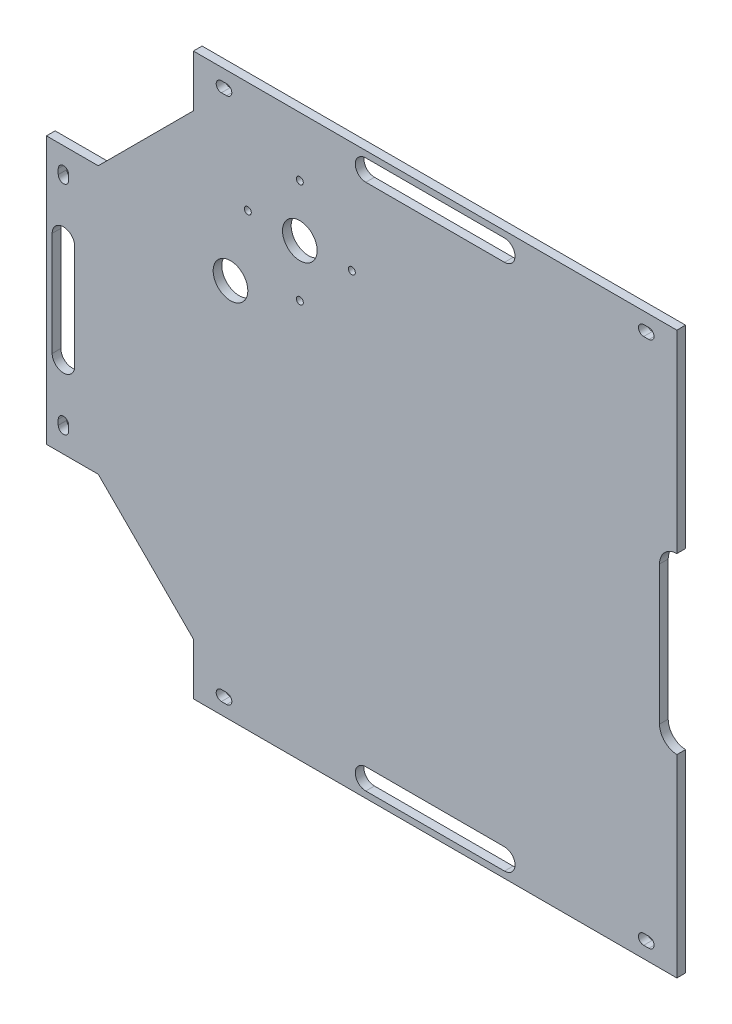
from build123d import *

# Parameters (mm, degrees)
SKETCH2_R           = 2
SKETCH2_R_2         = 10
BOSS_EXTRUDE6_DEPTH = 5
CUT_EXTRUDE9_DEPTH  = 10


with BuildPart() as part:
    # Sketch2 → Boss-Extrude6 (new body)
    with BuildSketch(Plane.XY):
        with BuildLine():
            Line((-130.703145502, -382.314175973), (-100.703145502, -382.314175973))
            Line((-100.703145502, -382.314175973), (-45.95440816, -327.565438631))
            Line((-45.95440816, -327.565438631), (-45.95440816, -297.565438631))
            Line((-45.95440816, -297.565438631), (233.296854498, -297.565438631))
            Line((233.296854498, -297.565438631), (233.296854498, -409.565438631))
            ThreePointArc((233.296854498, -409.565438631), (226.225786687, -412.494370819), (223.296854498, -419.565438631))
            Line((223.296854498, -419.565438631), (223.296854498, -499.565438631))
            ThreePointArc((223.296854498, -499.565438631), (226.225786687, -506.636506443), (233.296854498, -509.565438631))
            Line((233.296854498, -509.565438631), (233.296854498, -621.565438631))
            Line((233.296854498, -621.565438631), (-45.95440816, -621.565438631))
            Line((-45.95440816, -621.565438631), (-45.95440816, -591.565438631))
            Line((-45.95440816, -591.565438631), (-100.703145502, -536.81670129))
            Line((-100.703145502, -536.81670129), (-130.703145502, -536.81670129))
            Line((-130.703145502, -536.81670129), (-130.703145502, -382.314175973))
        make_face()
        with Locations((15.633601358, -331.79452168)):
            Circle(SKETCH2_R, mode=Mode.SUBTRACT)
        with Locations((-14.366398642, -361.79452168)):
            Circle(SKETCH2_R, mode=Mode.SUBTRACT)
        with Locations((15.633601358, -391.79452168)):
            Circle(SKETCH2_R, mode=Mode.SUBTRACT)
        with Locations((45.633601358, -361.79452168)):
            Circle(SKETCH2_R, mode=Mode.SUBTRACT)
        with Locations((15.633601358, -361.79452168)):
            Circle(SKETCH2_R_2, mode=Mode.SUBTRACT)
        with Locations((-24.366398642, -401.79452168)):
            Circle(SKETCH2_R_2, mode=Mode.SUBTRACT)
        with BuildLine():
            Line((-29.596250394, -304.524677965), (-26.596250394, -304.524677965))
            ThreePointArc((-26.596250394, -304.524677965), (-23.596250394, -307.524677965), (-26.596250394, -310.524677965))
            Line((-26.596250394, -310.524677965), (-29.596250394, -310.524677965))
            ThreePointArc((-29.596250394, -310.524677965), (-32.596250394, -307.524677965), (-29.596250394, -304.524677965))
        make_face(mode=Mode.SUBTRACT)
        with BuildLine():
            Line((-114.203145502, -429.565438631), (-114.203145502, -489.565438631))
            ThreePointArc((-114.203145502, -489.565438631), (-120.703145502, -496.065438631), (-127.203145502, -489.565438631))
            Line((-127.203145502, -489.565438631), (-127.203145502, -429.565438631))
            ThreePointArc((-127.203145502, -429.565438631), (-120.703145502, -423.065438631), (-114.203145502, -429.565438631))
        make_face(mode=Mode.SUBTRACT)
        with BuildLine():
            Line((216.938696732, -304.524677965), (213.938696732, -304.524677965))
            ThreePointArc((213.938696732, -304.524677965), (210.938696732, -307.524677965), (213.938696732, -310.524677965))
            Line((213.938696732, -310.524677965), (216.938696732, -310.524677965))
            ThreePointArc((216.938696732, -310.524677965), (219.938696732, -307.524677965), (216.938696732, -304.524677965))
        make_face(mode=Mode.SUBTRACT)
        with BuildLine():
            Line((216.938696732, -614.606199297), (213.938696732, -614.606199297))
            ThreePointArc((213.938696732, -614.606199297), (210.938696732, -611.606199297), (213.938696732, -608.606199297))
            Line((213.938696732, -608.606199297), (216.938696732, -608.606199297))
            ThreePointArc((216.938696732, -608.606199297), (219.938696732, -611.606199297), (216.938696732, -614.606199297))
        make_face(mode=Mode.SUBTRACT)
        with BuildLine():
            Line((-29.596250394, -614.606199297), (-26.596250394, -614.606199297))
            ThreePointArc((-26.596250394, -614.606199297), (-23.596250394, -611.606199297), (-26.596250394, -608.606199297))
            Line((-26.596250394, -608.606199297), (-29.596250394, -608.606199297))
            ThreePointArc((-29.596250394, -608.606199297), (-32.596250394, -611.606199297), (-29.596250394, -614.606199297))
        make_face(mode=Mode.SUBTRACT)
        with BuildLine():
            Line((-117.703145502, -395.473744081), (-117.703145502, -398.473744081))
            ThreePointArc((-117.703145502, -398.473744081), (-120.703145502, -401.473744081), (-123.703145502, -398.473744081))
            Line((-123.703145502, -398.473744081), (-123.703145502, -395.473744081))
            ThreePointArc((-123.703145502, -395.473744081), (-120.703145502, -392.473744081), (-117.703145502, -395.473744081))
        make_face(mode=Mode.SUBTRACT)
        with BuildLine():
            Line((53.671223169, -301.453147058), (133.671223169, -301.453147058))
            ThreePointArc((133.671223169, -301.453147058), (139.742754077, -307.524677965), (133.671223169, -313.596208873))
            Line((133.671223169, -313.596208873), (53.671223169, -313.596208873))
            ThreePointArc((53.671223169, -313.596208873), (47.599692262, -307.524677965), (53.671223169, -301.453147058))
        make_face(mode=Mode.SUBTRACT)
        with BuildLine():
            Line((-117.703145502, -523.657133181), (-117.703145502, -520.657133181))
            ThreePointArc((-117.703145502, -520.657133181), (-120.703145502, -517.657133181), (-123.703145502, -520.657133181))
            Line((-123.703145502, -520.657133181), (-123.703145502, -523.657133181))
            ThreePointArc((-123.703145502, -523.657133181), (-120.703145502, -526.657133181), (-117.703145502, -523.657133181))
        make_face(mode=Mode.SUBTRACT)
        with BuildLine():
            Line((53.671223169, -617.677730205), (133.671223169, -617.677730205))
            ThreePointArc((133.671223169, -617.677730205), (139.742754077, -611.606199297), (133.671223169, -605.534668389))
            Line((133.671223169, -605.534668389), (53.671223169, -605.534668389))
            ThreePointArc((53.671223169, -605.534668389), (47.599692262, -611.606199297), (53.671223169, -617.677730205))
        make_face(mode=Mode.SUBTRACT)
    extrude(amount=BOSS_EXTRUDE6_DEPTH)

    # Sketch5 → Cut-Extrude9 (cut)
    with BuildSketch(Plane.XY.offset(5)):
        with BuildLine():
            Line((-130.703145502, -382.314175973), (-130.703145502, -536.81670129))
            Line((-130.703145502, -536.81670129), (-100.703145502, -536.81670129))
            Line((-100.703145502, -536.81670129), (-45.95440816, -591.565438631))
            Line((-45.95440816, -591.565438631), (-45.95440816, -621.565438631))
            Line((-45.95440816, -621.565438631), (233.296854498, -621.565438631))
            Line((233.296854498, -621.565438631), (233.296854498, -509.565438631))
            ThreePointArc((233.296854498, -509.565438631), (226.225786687, -506.636506443), (223.296854498, -499.565438631))
            Line((223.296854498, -499.565438631), (223.296854498, -419.565438631))
            ThreePointArc((223.296854498, -419.565438631), (226.225786687, -412.494370819), (233.296854498, -409.565438631))
            Line((233.296854498, -409.565438631), (233.296854498, -297.565438631))
            Line((233.296854498, -297.565438631), (-45.95440816, -297.565438631))
            Line((-45.95440816, -297.565438631), (-45.95440816, -327.565438631))
            Line((-45.95440816, -327.565438631), (-100.703145502, -382.314175973))
            Line((-100.703145502, -382.314175973), (-130.703145502, -382.314175973))
        make_face()
        with BuildLine():
            Line((-45.75440816, -327.648281344), (-100.620302789, -382.514175973))
            Line((-100.620302789, -382.514175973), (-130.503145502, -382.514175973))
            Line((-130.503145502, -382.514175973), (-130.503145502, -536.61670129))
            Line((-130.503145502, -536.61670129), (-100.620302789, -536.61670129))
            Line((-100.620302789, -536.61670129), (-45.75440816, -591.482595919))
            Line((-45.75440816, -591.482595919), (-45.75440816, -621.365438631))
            Line((-45.75440816, -621.365438631), (233.096854498, -621.365438631))
            Line((233.096854498, -621.365438631), (233.096854498, -509.763477658))
            ThreePointArc((233.096854498, -509.763477658), (226.013997916, -506.70686706), (223.096854498, -499.565438631))
            Line((223.096854498, -499.565438631), (223.096854498, -419.565438631))
            ThreePointArc((223.096854498, -419.565438631), (226.013997916, -412.424010203), (233.096854498, -409.367399604))
            Line((233.096854498, -409.367399604), (233.096854498, -297.765438631))
            Line((233.096854498, -297.765438631), (-45.75440816, -297.765438631))
            Line((-45.75440816, -297.765438631), (-45.75440816, -327.648281344))
        make_face(mode=Mode.SUBTRACT)
    extrude(amount=-CUT_EXTRUDE9_DEPTH, mode=Mode.SUBTRACT)


solid = part.part
